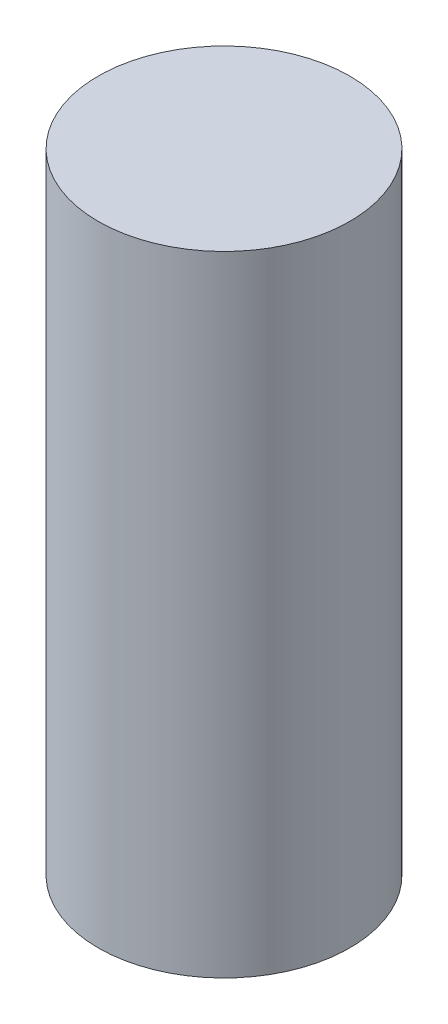
from build123d import *

# Parameters (mm, degrees)
SKETCH1_R           = 1
BOSS_EXTRUDE1_DEPTH = 5


with BuildPart() as part:
    # Sketch1 → Boss-Extrude1 (new body)
    with BuildSketch(Plane(origin=(0, 0, 0), x_dir=(1, 0, 0), z_dir=(0, 1, 0))):
        Circle(SKETCH1_R)
    extrude(amount=BOSS_EXTRUDE1_DEPTH)


solid = part.part
